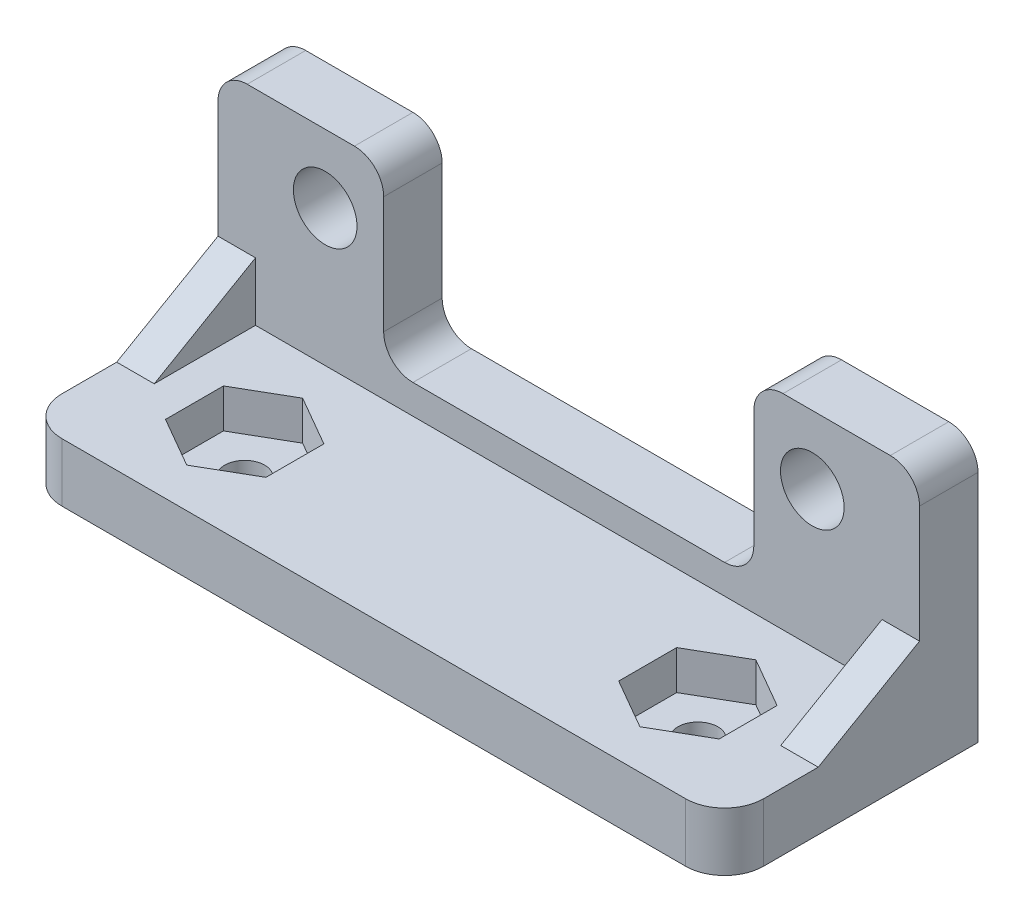
from build123d import *

# Parameters (mm, degrees)
BOSS_EXTRUDE1_DEPTH      = 3
SKETCH2_W                = 35.99
SKETCH2_H                = 3
BOSS_EXTRUDE2_DEPTH      = 13
F_4_CLEARANCE_HOLE1_D    = 3.2639
M2_5X0_45_TAPPED_HOLE1_D = 2.05
CUT_EXTRUDE1_DEPTH       = 25.557484093
CUT_EXTRUDE1_DEPTH_BACK  = 2
FILLET1_R                = 2
RIB1_REACH               = 41.551
SKETCH8_WALL_W           = 87.101962048
SKETCH8_WALL_H           = 1.925
FILLET2_R                = 1.5


with BuildPart() as part:
    # Sketch1 → Boss-Extrude1 (new body)
    with BuildSketch(Plane.XY):
        Polygon((-17.995, 3.5), (-17.995, 0), (-17.995, -10), (17.995, -10), (17.995, 0), (17.995, 3.5), (9.495, 3.5), (9.495, 0), (9.495, -5.5), (-9.495, -5.5), (-9.495, 0), (-9.495, 3.5), align=None)
    extrude(amount=BOSS_EXTRUDE1_DEPTH)

    # Sketch2 → Boss-Extrude2 (add)
    with BuildSketch(Plane.XY):
        with Locations((0, -8.5)):
            Rectangle(SKETCH2_W, SKETCH2_H)
    extrude(amount=BOSS_EXTRUDE2_DEPTH)

    # #4 Clearance Hole1 (through all)
    with Locations(Plane(origin=(0, 0, 0), x_dir=(-1, 0, 0), z_dir=(0, 0, -1))):
        with Locations((12.495, 0), (-12.495, 0)):
            Hole(F_4_CLEARANCE_HOLE1_D / 2)

    # M2.5x0.45 Tapped Hole1 (through all)
    with Locations(Plane(origin=(0, -7, 0), x_dir=(1, 0, 0), z_dir=(0, 1, 0))):
        with Locations((-11.625, -8), (11.625, -8)):
            Hole(M2_5X0_45_TAPPED_HOLE1_D / 2)

    # Sketch9 → Cut-Extrude1 (cut, two sides)
    with BuildSketch(Plane(origin=(0, -7, 0), x_dir=(1, 0, 0), z_dir=(0, 1, 0))) as cut_extrude1_sk:
        Polygon((-9.05, -6.513323057), (-11.625, -5.026646114), (-14.2, -6.513323057), (-14.2, -9.486676943), (-11.625, -10.973353886), (-9.05, -9.486676943), align=None)
        Polygon((11.625, -5.026646114), (9.05, -6.513323057), (9.05, -9.486676943), (11.625, -10.973353886), (14.2, -9.486676943), (14.2, -6.513323057), align=None)
    extrude(amount=CUT_EXTRUDE1_DEPTH, mode=Mode.SUBTRACT)
    extrude(cut_extrude1_sk.sketch, amount=-CUT_EXTRUDE1_DEPTH_BACK, mode=Mode.SUBTRACT)

    # Fillet1
    fillet1_edges = [part.edges().sort_by_distance(p)[0] for p in [
        (-17.995, -8.5, 13),
        (17.995, -8.5, 13),
    ]]
    fillet(fillet1_edges, radius=FILLET1_R)

    # Sketch8 wall → Rib1 (add, up to next)
    with BuildSketch(Plane(origin=(-17.995, -5.5, 5.598076211), x_dir=(0, -0.499999999979, 0.866025403797), z_dir=(0, 0.866025403797, 0.499999999979)), mode=Mode.PRIVATE) as rib1_sk1:
        with Locations((0, 0.9625)):
            Rectangle(SKETCH8_WALL_W, SKETCH8_WALL_H)
    rib1_tool1 = extrude(rib1_sk1.sketch, amount=-RIB1_REACH, mode=Mode.PRIVATE) - part.part
    rib1 = rib1_tool1.solids().sort_by_distance((-17.995, -5.5, 5.598076211))[0]
    add(rib1)

    # Mirror1: Rib1 across plane
    add(rib1.mirror(Plane(origin=(0, 0, 0), x_dir=(0, 0, 1), z_dir=(1, 0, 0))))

    # Fillet2
    fillet2_edges = [part.edges().sort_by_distance(p)[0] for p in [
        (9.495, 3.5, 1.5),
        (9.495, -5.5, 1.5),
        (-9.495, -5.5, 1.5),
        (-9.495, 3.5, 1.5),
        (-17.995, 3.5, 1.5),
        (17.995, 3.5, 1.5),
    ]]
    fillet(fillet2_edges, radius=FILLET2_R)


solid = part.part
